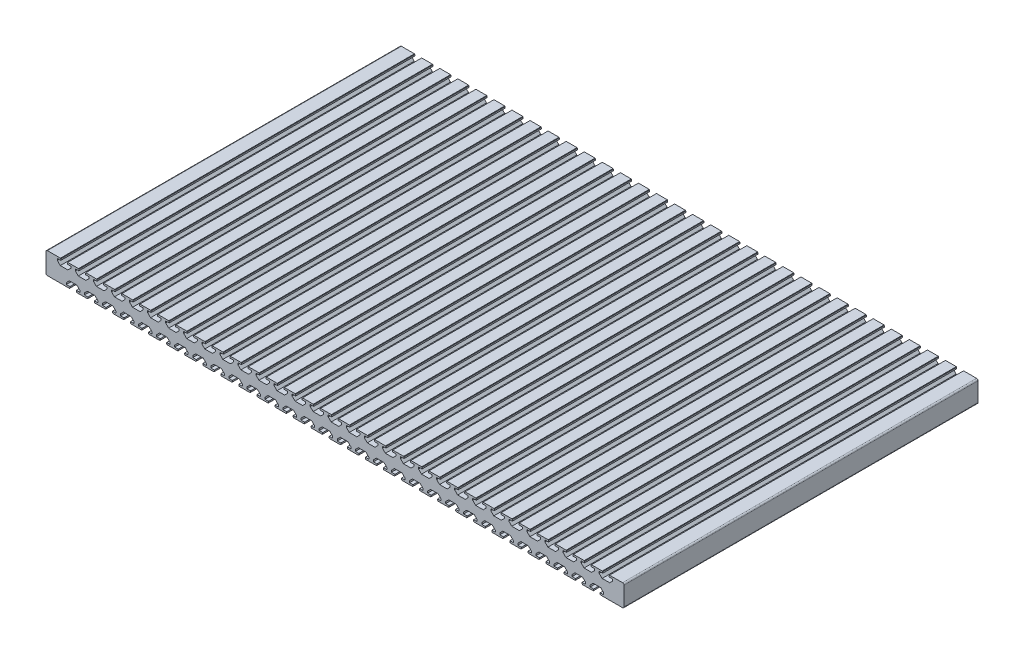
from build123d import *

# Parameters (mm, degrees)
SKETCH1_W           = 800
SKETCH1_H           = 490
BOSS_EXTRUDE1_DEPTH = 30
CUT_EXTRUDE1_DEPTH  = 491
LPATTERN1_COUNT     = 31
LPATTERN1_PITCH     = 25
CUT_EXTRUDE2_DEPTH  = 491
LPATTERN2_COUNT     = 30
LPATTERN2_PITCH     = 25
FILLET1_R           = 2


with BuildPart() as part:
    # Sketch1 → Boss-Extrude1 (new body)
    with BuildSketch(Plane(origin=(0, 0, 0), x_dir=(1, 0, 0), z_dir=(0, 1, 0))):
        with Locations((400, 245)):
            Rectangle(SKETCH1_W, SKETCH1_H)
    extrude(amount=BOSS_EXTRUDE1_DEPTH)

    # Sketch2 → Cut-Extrude1 (cut, through all)
    with BuildSketch(Plane.XY):
        Polygon((29.5, 30), (20.5, 30), (20.5, 29.5), (20.5, 27.55), (15.65, 27.55), (15.65, 25.1), (19.75, 21), (30.25, 21), (34.35, 25.1), (34.35, 27.55), (29.5, 27.55), (29.5, 29.5), align=None)
        with BuildLine():
            Line((20.5, 29.5), (20.5, 30))
            Line((20.5, 30), (20, 30))
            ThreePointArc((20, 30), (20.146446609, 29.646446609), (20.5, 29.5))
        make_face()
        with BuildLine():
            Line((30, 30), (29.5, 30))
            Line((29.5, 30), (29.5, 29.5))
            ThreePointArc((29.5, 29.5), (29.853553391, 29.646446609), (30, 30))
        make_face()
    cut_extrude1 = extrude(amount=-CUT_EXTRUDE1_DEPTH, mode=Mode.SUBTRACT)

    # LPattern1: Cut-Extrude1 ×31
    with Locations(*[(i * LPATTERN1_PITCH, 0, 0) for i in range(1, LPATTERN1_COUNT)]):
        add(cut_extrude1, mode=Mode.SUBTRACT)

    # Sketch3 → Cut-Extrude2 (cut, through all)
    with BuildSketch(Plane.XY):
        Polygon((42, 0), (33, 0), (33, 2.45), (28.15, 2.45), (28.15, 4.9), (32.25, 9), (42.75, 9), (46.85, 4.9), (46.85, 2.45), (42, 2.45), align=None)
        with BuildLine():
            Line((33, 0.5), (33, 0))
            Line((33, 0), (32.5, 0))
            ThreePointArc((32.5, 0), (32.646446609, 0.353553391), (33, 0.5))
        make_face()
        with BuildLine():
            Line((42, 0), (42.5, 0))
            ThreePointArc((42.5, 0), (42.353553391, 0.353553391), (42, 0.5))
            Line((42, 0.5), (42, 0))
        make_face()
    cut_extrude2 = extrude(amount=-CUT_EXTRUDE2_DEPTH, mode=Mode.SUBTRACT)

    # LPattern2: Cut-Extrude2 ×30
    with Locations(*[(i * LPATTERN2_PITCH, 0, 0) for i in range(1, LPATTERN2_COUNT)]):
        add(cut_extrude2, mode=Mode.SUBTRACT)

    # Fillet1
    fillet1_edges = [part.edges().sort_by_distance(p)[0] for p in [
        (800, 30, -245),
        (0, 30, -245),
        (800, 0, -245),
        (0, 0, -245),
    ]]
    fillet(fillet1_edges, radius=FILLET1_R)


solid = part.part
